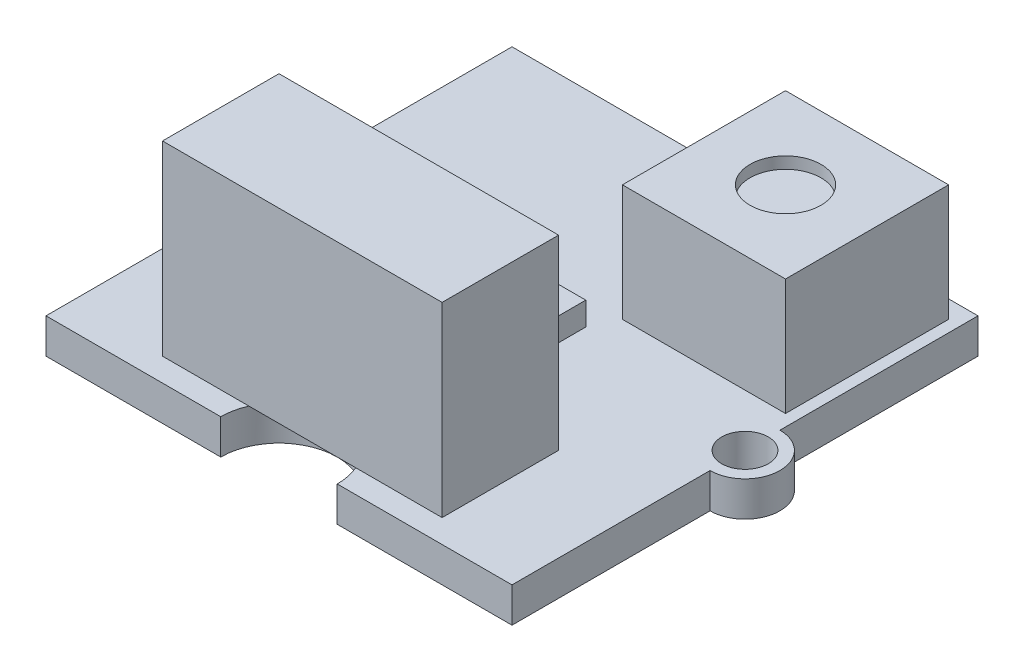
from build123d import *

# Parameters (mm, degrees)
SKETCH2_W                       = 20
SKETCH2_H                       = 20
PCB_DEPTH                       = 1.5
SKETCH3_R                       = 1.5
SIDE_MOUNTING_HOLES_FRAME_DEPTH = 1.5
SKETCH4_R                       = 1
SIDE_MOUNTING_HOLES_DEPTH       = 1.5
SKETCH5_R                       = 2.5
SIDE_INLETS_DEPTH               = 1.5
SKETCH6_W                       = 12
SKETCH6_H                       = 5
BOSS_EXTRUDE3_DEPTH             = 8
SKETCH7_W                       = 7
SKETCH7_H                       = 7
BOSS_EXTRUDE4_DEPTH             = 5
SKETCH8_R                       = 1.522673679
CUT_EXTRUDE3_DEPTH              = 0.5
SKETCH9_W                       = 5
SKETCH9_H                       = 3.5
BOSS_EXTRUDE5_DEPTH             = 1


with BuildPart() as part:
    # Sketch2 → pcb (new body)
    with BuildSketch(Plane(origin=(0, 0, 0), x_dir=(1, 0, 0), z_dir=(0, 1, 0))):
        Rectangle(SKETCH2_W, SKETCH2_H)
    extrude(amount=PCB_DEPTH)

    # Sketch3 → side mounting holes frame (add)
    with BuildSketch(Plane(origin=(0, 1.5, 0), x_dir=(1, 0, 0), z_dir=(0, 1, 0))):
        with Locations((-10, 0)):
            Circle(SKETCH3_R)
        with Locations((10, 0)):
            Circle(SKETCH3_R)
    extrude(amount=-SIDE_MOUNTING_HOLES_FRAME_DEPTH)

    # Sketch4 → side mounting holes (cut)
    with BuildSketch(Plane(origin=(0, 1.5, 0), x_dir=(1, 0, 0), z_dir=(0, 1, 0))):
        with Locations((-10, 0)):
            Circle(SKETCH4_R)
        with Locations((10, 0)):
            Circle(SKETCH4_R)
    extrude(amount=-SIDE_MOUNTING_HOLES_DEPTH, mode=Mode.SUBTRACT)

    # Sketch5 → side inlets (cut)
    with BuildSketch(Plane(origin=(0, 1.5, 0), x_dir=(1, 0, 0), z_dir=(0, 1, 0))):
        with Locations((0, 10)):
            Circle(SKETCH5_R)
        with Locations((0, -10)):
            Circle(SKETCH5_R)
    extrude(amount=-SIDE_INLETS_DEPTH, mode=Mode.SUBTRACT)

    # Sketch6 → Boss-Extrude3 (add)
    with BuildSketch(Plane(origin=(0, 1.5, 0), x_dir=(1, 0, 0), z_dir=(0, 1, 0))):
        with Locations((0, -6.5)):
            Rectangle(SKETCH6_W, SKETCH6_H)
    extrude(amount=BOSS_EXTRUDE3_DEPTH)

    # Sketch7 → Boss-Extrude4 (add)
    with BuildSketch(Plane(origin=(0, 1.5, 0), x_dir=(1, 0, 0), z_dir=(0, 1, 0))):
        with Locations((6, 5.738753886)):
            Rectangle(SKETCH7_W, SKETCH7_H)
    extrude(amount=BOSS_EXTRUDE4_DEPTH)

    # Sketch8 → Cut-Extrude3 (cut)
    with BuildSketch(Plane(origin=(0, 6.5, 0), x_dir=(1, 0, 0), z_dir=(0, 1, 0))):
        with Locations((6, 5.738753886)):
            Circle(SKETCH8_R)
    extrude(amount=-CUT_EXTRUDE3_DEPTH, mode=Mode.SUBTRACT)

    # Sketch9 → Boss-Extrude5 (add)
    with BuildSketch(Plane(origin=(0, 1.5, 0), x_dir=(1, 0, 0), z_dir=(0, 1, 0))):
        with Locations((-0.5, -0.582791265)):
            Rectangle(SKETCH9_W, SKETCH9_H)
    extrude(amount=BOSS_EXTRUDE5_DEPTH)


solid = part.part
